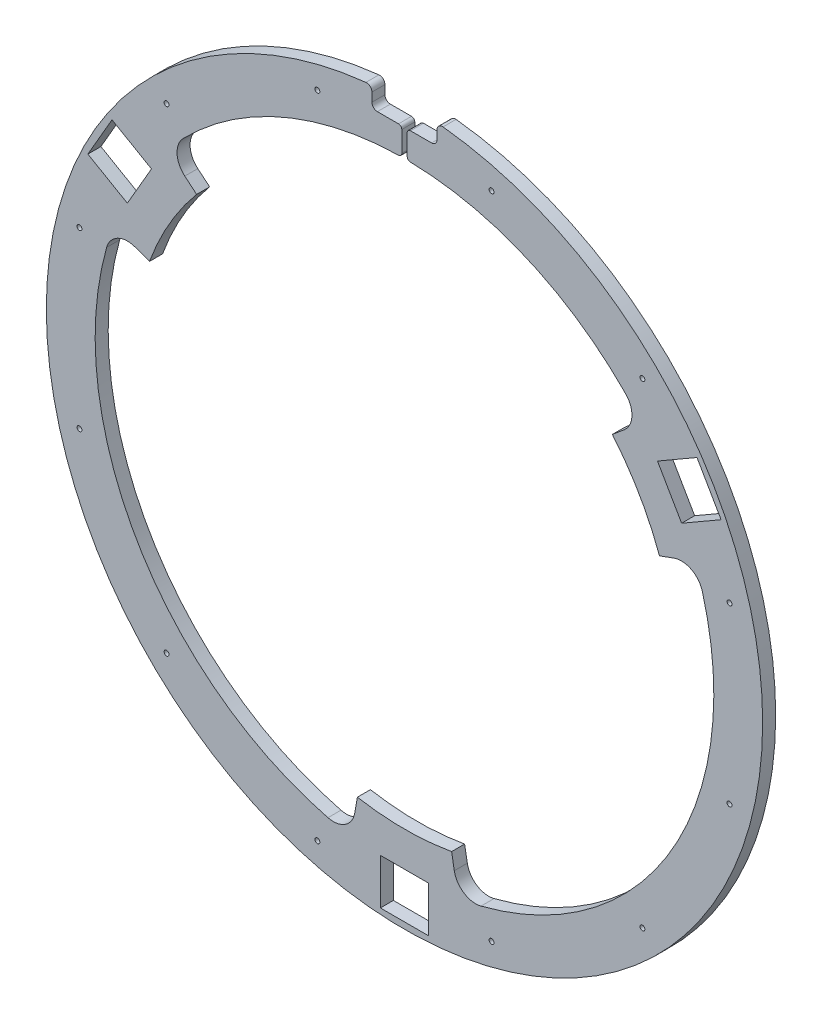
from build123d import *

# Parameters (mm, degrees)
SKETCH2_R                                      = 330
SKETCH2_R_2                                    = 250
SKETCH2_W                                      = 44.45
SKETCH2_H                                      = 42
BOSS_EXTRUDE1_DEPTH                            = 12
CUT_EXTRUDE1_DEPTH                             = 12
SKETCH5_W                                      = 60
SKETCH5_H                                      = 60
CUT_EXTRUDE2_DEPTH                             = 12
FILLET1_R                                      = 5
SKETCH6_W                                      = 5
SKETCH6_H                                      = 30
CUT_EXTRUDE3_DEPTH                             = 12
FILLET2_R                                      = 3
CSK_FOR_M4_FLAT_HEAD_MACHINE_SCREW_D           = 4.5
CSK_FOR_M4_FLAT_HEAD_MACHINE_SCREW_CSINK_D     = 9.4
CSK_FOR_M4_FLAT_HEAD_MACHINE_SCREW_CSINK_ANGLE = 90


with BuildPart() as part:
    # Sketch2 → Boss-Extrude1 (new body)
    with BuildSketch(Plane.XY.offset(-518.360637908)):
        Circle(SKETCH2_R)
        Circle(SKETCH2_R_2, mode=Mode.SUBTRACT)
        with Locations((0, -303)):
            Rectangle(SKETCH2_W, SKETCH2_H, mode=Mode.SUBTRACT)
        Polygon((269.479730826, 181.247414599), (233.106663867, 160.247414599), (255.331663867, 121.752585401), (291.704730826, 142.752585401), align=None, mode=Mode.SUBTRACT)
        Polygon((-291.704730826, 142.752585401), (-255.331663867, 121.752585401), (-233.106663867, 160.247414599), (-269.479730826, 181.247414599), align=None, mode=Mode.SUBTRACT)
    extrude(amount=BOSS_EXTRUDE1_DEPTH)

    # Sketch3 → Cut-Extrude1 (cut)
    with BuildSketch(Plane.XY.offset(-506.360637908)):
        with BuildLine():
            Line((191.51111078, 160.696902422), (202.422805046, 169.852901056))
            ThreePointArc((202.422805046, 169.852901056), (209.542560602, 184.184300077), (203.874000238, 199.14917029))
            ThreePointArc((203.874000238, 199.14917029), (0, 285), (-203.874000238, 199.14917029))
            ThreePointArc((-203.874000238, 199.14917029), (-209.542560602, 184.184300077), (-202.422805046, 169.852901056))
            Line((-202.422805046, 169.852901056), (-191.51111078, 160.696902422))
            ThreePointArc((-191.51111078, 160.696902422), (0, 250), (191.51111078, 160.696902422))
        make_face()
        with BuildLine():
            Line((43.412044417, -246.201938253), (45.885524698, -260.229742003))
            ThreePointArc((45.885524698, -260.229742003), (54.737002544, -273.561330694), (70.531240495, -276.134648522))
            ThreePointArc((70.531240495, -276.134648522), (246.817240079, -142.5), (274.405240732, 76.985478232))
            ThreePointArc((274.405240732, 76.985478232), (264.279563146, 89.377030617), (248.308329744, 90.376840947))
            Line((248.308329744, 90.376840947), (234.923155196, 85.505035831))
            ThreePointArc((234.923155196, 85.505035831), (216.506350946, -125), (43.412044417, -246.201938253))
        make_face()
        with BuildLine():
            Line((-234.923155196, 85.505035831), (-248.308329744, 90.376840947))
            ThreePointArc((-248.308329744, 90.376840947), (-264.279563146, 89.377030617), (-274.405240732, 76.985478232))
            ThreePointArc((-274.405240732, 76.985478232), (-246.817240079, -142.5), (-70.531240495, -276.134648522))
            ThreePointArc((-70.531240495, -276.134648522), (-54.737002544, -273.561330694), (-45.885524698, -260.229742003))
            Line((-45.885524698, -260.229742003), (-43.412044417, -246.201938253))
            ThreePointArc((-43.412044417, -246.201938253), (-216.506350946, -125), (-234.923155196, 85.505035831))
        make_face()
    extrude(amount=-CUT_EXTRUDE1_DEPTH, mode=Mode.SUBTRACT)

    # Sketch5 → Cut-Extrude2 (cut)
    with BuildSketch(Plane.XY.offset(-506.360637908)):
        with Locations((0, 340)):
            Rectangle(SKETCH5_W, SKETCH5_H)
    extrude(amount=-CUT_EXTRUDE2_DEPTH, mode=Mode.SUBTRACT)

    # Fillet1
    fillet1_edges = [part.edges().sort_by_distance(p)[0] for p in [
        (30, 328.633534503, -512.360637908),
        (-30, 328.633534503, -512.360637908),
        (-30, 310, -512.360637908),
        (30, 310, -512.360637908),
    ]]
    fillet(fillet1_edges, radius=FILLET1_R)

    # Sketch6 → Cut-Extrude3 (cut)
    with BuildSketch(Plane.XY.offset(-506.360637908)):
        with Locations((0, 295)):
            Rectangle(SKETCH6_W, SKETCH6_H)
    extrude(amount=-CUT_EXTRUDE3_DEPTH, mode=Mode.SUBTRACT)

    # Fillet2
    fillet2_edges = [part.edges().sort_by_distance(p)[0] for p in [
        (2.5, 284.989034877, -512.360637908),
        (2.5, 310, -512.360637908),
        (-2.5, 284.989034877, -512.360637908),
        (-2.5, 310, -512.360637908),
    ]]
    fillet(fillet2_edges, radius=FILLET2_R)

    # CSK for M4 Flat Head Machine Screw (through all)
    with Locations(Plane(origin=(0, 0, -530.360637908), x_dir=(1, 0, 0), z_dir=(0, 0, -1))):
        with Locations((80.233903982, 299.43700615), (219.203102168, 219.203102168), (299.43700615, 80.233903982), (299.43700615, -80.233903982), (219.203102168, -219.203102168), (80.233903982, -299.43700615), (-80.233903982, -299.43700615), (-219.203102168, -219.203102168), (-299.43700615, -80.233903982), (-299.43700615, 80.233903982), (-219.203102168, 219.203102168), (-80.233903982, 299.43700615), (0, 0)):
            CounterSinkHole(CSK_FOR_M4_FLAT_HEAD_MACHINE_SCREW_D / 2, CSK_FOR_M4_FLAT_HEAD_MACHINE_SCREW_CSINK_D / 2, counter_sink_angle=CSK_FOR_M4_FLAT_HEAD_MACHINE_SCREW_CSINK_ANGLE)


solid = part.part
